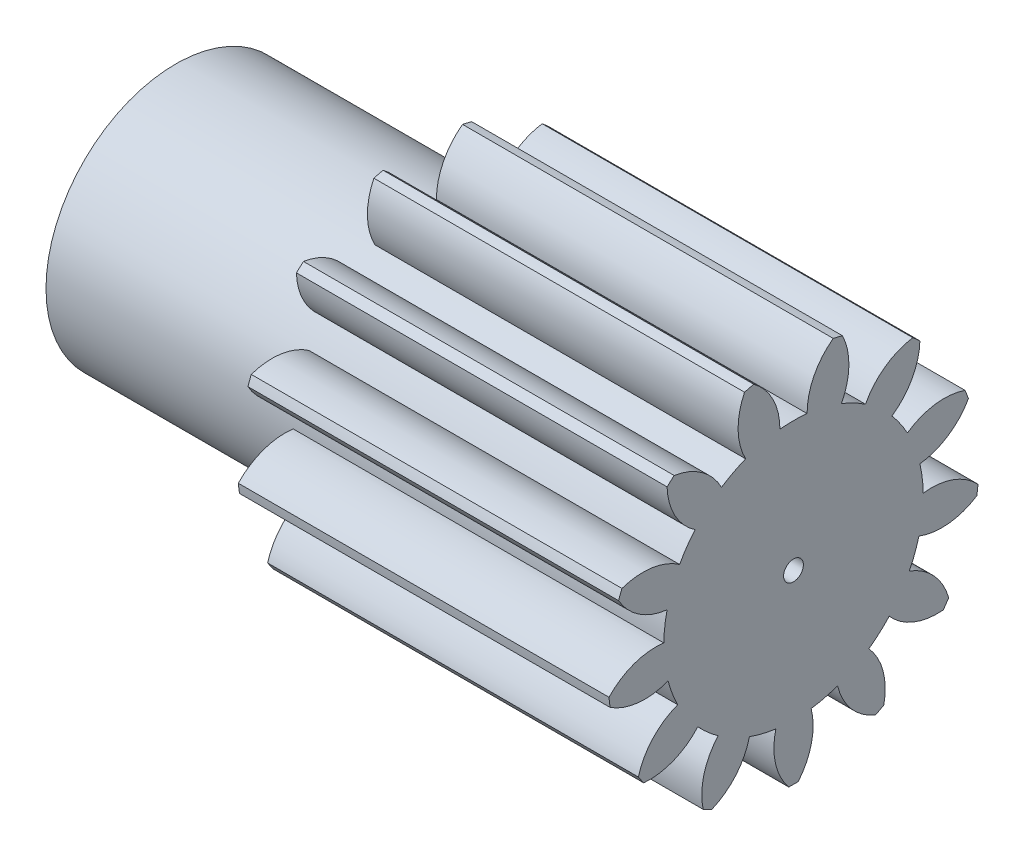
from build123d import *
from build123d.topology import SkipClean

# Parameters (mm, degrees)
BASPROSKE_W      = 15
BASPROSKE_H      = 7.5
TOOTHCUT_DEPTH   = 19.371173071
TEETHCUTS_COUNT  = 13
TEETHCUTS_ANGLE  = 332.307692308
HUBNEAONESKE_R   = 5.249
HUBNEARONE_DEPTH = 10.0000508
BORSKE_R         = 0.4
BORE_DEPTH       = 25.0000508


with BuildPart() as part:
    # BasProSke → Base-Revolve (revolve)
    with BuildSketch(Plane(origin=(0, 0, 0), x_dir=(1, 0, 0), z_dir=(0, 1, 0)), mode=Mode.PRIVATE) as base_revolve_sk:
        with Locations((7.5, 3.75)):
            Rectangle(BASPROSKE_W, BASPROSKE_H)
    revolve(base_revolve_sk.sketch.rotate(Axis((-10, 0, 0), (1, 0, 0)), 180), axis=Axis((-10, 0, 0), (1, 0, 0)))

    # TooCutSke → ToothCut (cut, through all)
    with BuildSketch(Plane(origin=(0, 0, 0), x_dir=(0, 0, -1), z_dir=(1, 0, 0))):
        with BuildLine():
            ThreePointArc((0.550489643, 5.220053846), (0, 5.249), (-0.550489643, 5.220053846))
            ThreePointArc((-0.550489643, 5.220053846), (-0.834571714, 6.414617604), (-1.635166801, 7.345602405))
            ThreePointArc((-1.635166801, 7.345602405), (0, 7.5254), (1.635166801, 7.345602405))
            ThreePointArc((1.635166801, 7.345602405), (0.834571714, 6.414617604), (0.550489643, 5.220053846))
        make_face()
    toothcut = extrude(amount=TOOTHCUT_DEPTH, mode=Mode.SUBTRACT)

    # TeethCuts: ToothCut ×13 about axis
    teethcuts_axis = Axis((-10, 0, 0), (1, 0, 0))
    for i in range(1, TEETHCUTS_COUNT):
        add(toothcut.rotate(teethcuts_axis, i * TEETHCUTS_ANGLE / (TEETHCUTS_COUNT - 1)), mode=Mode.SUBTRACT)

    # HubNeaOneSke → HubNearOne (add)
    with SkipClean():  # the faces are left unmerged after this step: merging them gives an invalid solid
        with BuildSketch(Plane.ZY):
            Circle(HUBNEAONESKE_R)
        extrude(amount=HUBNEARONE_DEPTH)

    # BorSke → Bore (cut, symmetric)
    with SkipClean():  # the faces are left unmerged after this step: merging them gives an invalid solid
        with BuildSketch(Plane(origin=(0, 0, 0), x_dir=(0, 0, -1), z_dir=(1, 0, 0))):
            with Locations(Location((0, 0, 0), (0, 0, 180))):
                Circle(BORSKE_R)
        extrude(amount=BORE_DEPTH, both=True, mode=Mode.SUBTRACT)


solid = part.part
